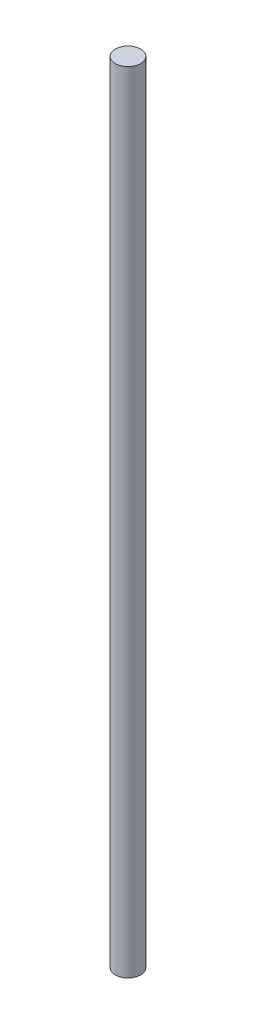
from build123d import *

# Parameters (mm, degrees)
SKETCH1_R           = 4
BOSS_EXTRUDE1_DEPTH = 250


with BuildPart() as part:
    # Sketch1 → Boss-Extrude1 (new body)
    with BuildSketch(Plane(origin=(0, 0, 0), x_dir=(1, 0, 0), z_dir=(0, 1, 0))):
        with Locations((-5.134075541, 4.655475279)):
            Circle(SKETCH1_R)
    extrude(amount=BOSS_EXTRUDE1_DEPTH)


solid = part.part
